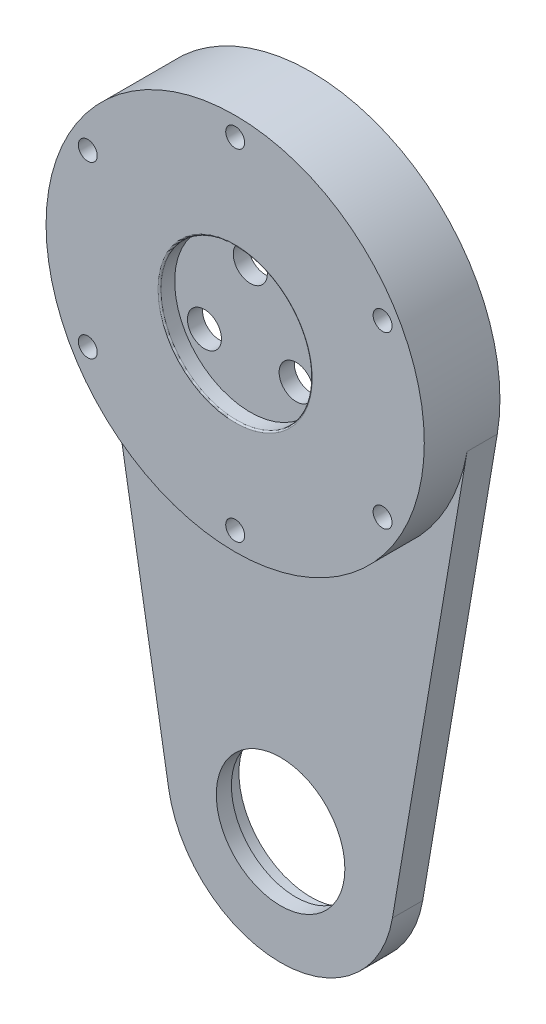
from build123d import *

# Parameters (mm, degrees)
SKETCH_2_R                   = 25
EXTRUDE_2_DEPTH              = 4
SKETCH_22_R                  = 10
CUT_EXTRUDE_1_DEPTH          = 2
FILLET_4_R                   = 0.2
SKETCH_54_R                  = 25
EXTRUDE_6_DEPTH              = 11
SKETCH_55_R                  = 18.5
CUT_EXTRUDE_2_DEPTH          = 10
HOLE_WIZARD_M4_1_D           = 4.5
HOLE_WIZARD_M4_1_CBORE_D     = 8
HOLE_WIZARD_M4_1_CBORE_DEPTH = 1
PATTERN_CIRCULAR_1_COUNT     = 3
SKETCH_59_R                  = 18.5
SKETCH_59_R_2                = 17.5
EXTRUDE_7_DEPTH              = 1
EXTRUDE_START                = -9
EXTRUDE_8_DEPTH              = 9
FILLET_6_R                   = 0.3
SKETCH_68_R                  = 9.5
CUT_EXTRUDE_7_DEPTH          = 7
SKETCH_69_R                  = 8.5
CUT_EXTRUDE_8_DEPTH          = 2
CUT_EXTRUDE_START            = -75
SKETCH_80_W                  = 72.028937147
SKETCH_80_H                  = 9.617570508
CUT_EXTRUDE_9_DEPTH          = 100
EXTRUDE_START_2              = -2
SKETCH_82_R                  = 9.5
SKETCH_82_R_2                = 8.5
EXTRUDE_9_DEPTH              = 2
PATTERN_CIRCULAR_2_COUNT     = 6


with BuildPart() as part:
    # Sketch 2 → Extrude 2 (new body)
    with BuildSketch(Plane(origin=(0, 6, 0), x_dir=(1, 0, 0), z_dir=(0, 0, -1))):
        with Locations((0, 6)):
            Circle(SKETCH_2_R)
    extrude(amount=EXTRUDE_2_DEPTH)

    # Sketch 22 → Cut-Extrude 1 (cut)
    with BuildSketch(Plane.XY):
        Circle(SKETCH_22_R)
    extrude(amount=-CUT_EXTRUDE_1_DEPTH, mode=Mode.SUBTRACT)

    # Fillet 4
    fillet_4_edges = [part.edges().sort_by_distance(p)[0] for p in [
        (-10, 0, 0),
    ]]
    fillet(fillet_4_edges, radius=FILLET_4_R)

    # Sketch 54 → Extrude 6 (add)
    with BuildSketch(Plane(origin=(0, 0, -4), x_dir=(-1, 0, 0), z_dir=(0, 0, -1))):
        Circle(SKETCH_54_R)
    extrude(amount=EXTRUDE_6_DEPTH)

    # Sketch 55 → Cut-Extrude 2 (cut)
    with BuildSketch(Plane(origin=(0, 0, -15), x_dir=(-1, 0, 0), z_dir=(0, 0, -1))):
        Circle(SKETCH_55_R)
    extrude(amount=-CUT_EXTRUDE_2_DEPTH, mode=Mode.SUBTRACT)

    # Hole Wizard M4 _ _ _ _ _ _1 (through all)
    with Locations(Plane(origin=(0, 0, -5), x_dir=(-1, 0, 0), z_dir=(0, 0, -1))):
        with Locations((0, 7)):
            hole_wizard_m4_1 = CounterBoreHole(HOLE_WIZARD_M4_1_D / 2, HOLE_WIZARD_M4_1_CBORE_D / 2, HOLE_WIZARD_M4_1_CBORE_DEPTH)

    # Pattern Circular 1: Hole Wizard M4 _ _ _ _ _ _1 ×3 about axis
    pattern_circular_1_axis = Axis((0, 0, 0), (0, 0, 1))
    for i in range(1, PATTERN_CIRCULAR_1_COUNT):
        add(hole_wizard_m4_1.rotate(pattern_circular_1_axis, i * 360 / PATTERN_CIRCULAR_1_COUNT), mode=Mode.SUBTRACT)

    # Sketch 59 → Extrude 7 (add)
    with BuildSketch(Plane(origin=(0, 0, -5), x_dir=(-1, 0, 0), z_dir=(0, 0, -1))):
        Circle(SKETCH_59_R)
        Circle(SKETCH_59_R_2, mode=Mode.SUBTRACT)
    extrude(amount=EXTRUDE_7_DEPTH)

    # Sketch 60 → Extrude 8 (add)
    with BuildSketch(Plane(origin=(0, 0, -15), x_dir=(-1, 0, 0), z_dir=(0, 0, -1)).offset(EXTRUDE_START)):
        with BuildLine():
            Line((-24.65033243, -4.166666667), (-14.790199458, -62.5))
            ThreePointArc((-14.790199458, -62.5), (0, -75), (14.790199458, -62.5))
            Line((14.790199458, -62.5), (24.65033243, -4.166666667))
            ThreePointArc((24.65033243, -4.166666667), (0, -25), (-24.65033243, -4.166666667))
        make_face()
    extrude(amount=EXTRUDE_8_DEPTH)

    # Fillet 6
    fillet_6_edges = [part.edges().sort_by_distance(p)[0] for p in [
        (18.5, 0, -6),
    ]]
    fillet(fillet_6_edges, radius=FILLET_6_R)

    # Sketch 68 → Cut-Extrude 7 (cut)
    with BuildSketch(Plane.XY.offset(-6)):
        with Locations((0, -60)):
            Circle(SKETCH_68_R)
    extrude(amount=-CUT_EXTRUDE_7_DEPTH, mode=Mode.SUBTRACT)

    # Sketch 69 → Cut-Extrude 8 (cut)
    with BuildSketch(Plane.XY.offset(-13)):
        with Locations((0, -60)):
            Circle(SKETCH_69_R)
    extrude(amount=-CUT_EXTRUDE_8_DEPTH, mode=Mode.SUBTRACT)

    # Sketch 80 → Cut-Extrude 9 (cut)
    with BuildSketch(Plane(origin=(0, 0, 0), x_dir=(1, 0, 0), z_dir=(0, 1, 0)).offset(CUT_EXTRUDE_START)):
        with Locations((0.446829634, 14.808785254)):
            Rectangle(SKETCH_80_W, SKETCH_80_H)
    extrude(amount=CUT_EXTRUDE_9_DEPTH, mode=Mode.SUBTRACT)

    # Sketch 82 → Extrude 9 (add)
    with BuildSketch(Plane.XY.offset(-6).offset(EXTRUDE_START_2)):
        with Locations((0, -60)):
            Circle(SKETCH_82_R)
        with Locations((0, -60)):
            Circle(SKETCH_82_R_2, mode=Mode.SUBTRACT)
    extrude(amount=EXTRUDE_9_DEPTH)

    # Sketch 87 → Hole Wizard M3 _ _ _ _1 (revolve, cut)
    with BuildSketch(Plane(origin=(0, 22.5, -10), x_dir=(0, 1, 0), z_dir=(1, 0, 0))):
        Polygon((0, 0), (0, 222.751075774), (1.25, 222), (1.25, 0), align=None)
    hole_wizard_m3_1 = revolve(axis=Axis((0, 22.5, -16.35), (0, 0, 1)), mode=Mode.SUBTRACT)

    # Pattern Circular 2: Hole Wizard M3 _ _ _ _1 ×6 about axis
    pattern_circular_2_axis = Axis((0, 0, 0), (0, 0, 1))
    for i in range(1, PATTERN_CIRCULAR_2_COUNT):
        add(hole_wizard_m3_1.rotate(pattern_circular_2_axis, i * 360 / PATTERN_CIRCULAR_2_COUNT), mode=Mode.SUBTRACT)


solid = part.part
